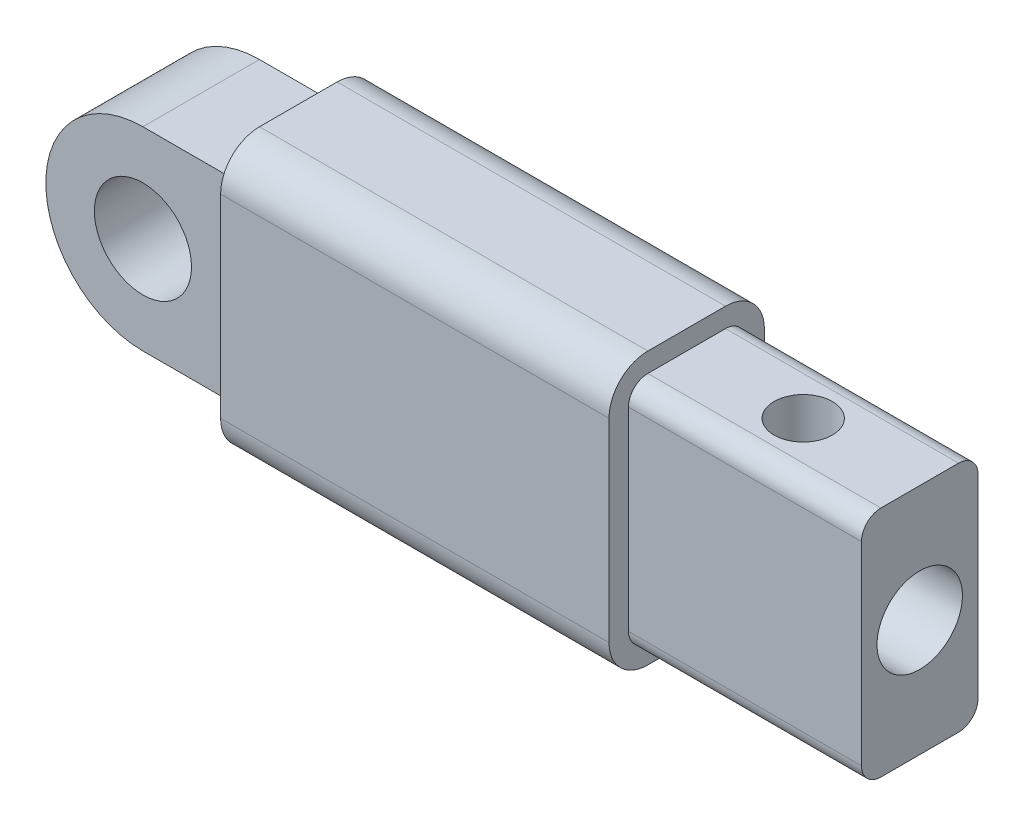
from build123d import *

# Parameters (mm, degrees)
STRUCTURAL_MEMBER1_DEPTH = 100
BOSS_EXTRUDE1_DEPTH      = 60
BOSS_EXTRUDE1_DEPTH_BACK = 150
SKETCH20_R               = 11
CUT_EXTRUDE6_DEPTH       = 30
SKETCH21_R               = 7.5
CUT_EXTRUDE7_DEPTH       = 174.853386507
CUT_EXTRUDE11_DEPTH      = 168.48134234
CUT_EXTRUDE11_DEPTH_BACK = 168.48134234
SKETCH23_R               = 12.5
CUT_EXTRUDE12_DEPTH      = 168.48134234


with BuildPart() as part:
    # Sketch11 → Structural Member1 (new body)
    with BuildSketch(Plane(origin=(0, 0, 0), x_dir=(0, 0, -1), z_dir=(1, 0, 0))):
        with BuildLine():
            Line((-10, -35), (10, -35))
            ThreePointArc((10, -35), (17.071067812, -32.071067812), (20, -25))
            Line((20, -25), (20, 25))
            ThreePointArc((20, 25), (17.071067812, 32.071067812), (10, 35))
            Line((10, 35), (-10, 35))
            ThreePointArc((-10, 35), (-17.071067812, 32.071067812), (-20, 25))
            Line((-20, 25), (-20, -25))
            ThreePointArc((-20, -25), (-17.071067812, -32.071067812), (-10, -35))
        make_face()
        with BuildLine():
            Line((-10, -30), (10, -30))
            ThreePointArc((10, -30), (13.535533906, -28.535533906), (15, -25))
            Line((15, -25), (15, 25))
            ThreePointArc((15, 25), (13.535533906, 28.535533906), (10, 30))
            Line((10, 30), (-10, 30))
            ThreePointArc((-10, 30), (-13.535533906, 28.535533906), (-15, 25))
            Line((-15, 25), (-15, -25))
            ThreePointArc((-15, -25), (-13.535533906, -28.535533906), (-10, -30))
        make_face(mode=Mode.SUBTRACT)
    extrude(amount=STRUCTURAL_MEMBER1_DEPTH)


with BuildPart() as body_2:
    # Sketch16 → Boss-Extrude1 (new, two sides)
    with BuildSketch(Plane(origin=(100, 0, 0), x_dir=(0, 0, -1), z_dir=(1, 0, 0))) as boss_extrude1_sk:
        with BuildLine():
            Line((15, -25), (15, 25))
            ThreePointArc((15, 25), (13.535533906, 28.535533906), (10, 30))
            Line((10, 30), (-10, 30))
            ThreePointArc((-10, 30), (-13.535533906, 28.535533906), (-15, 25))
            Line((-15, 25), (-15, -25))
            ThreePointArc((-15, -25), (-13.535533906, -28.535533906), (-10, -30))
            Line((-10, -30), (10, -30))
            ThreePointArc((10, -30), (13.535533906, -28.535533906), (15, -25))
        make_face()
    extrude(amount=BOSS_EXTRUDE1_DEPTH)
    extrude(boss_extrude1_sk.sketch, amount=-BOSS_EXTRUDE1_DEPTH_BACK)

    # Sketch20 → Cut-Extrude6 (cut)
    with BuildSketch(Plane(origin=(160, 0, 0), x_dir=(0, 0, -1), z_dir=(1, 0, 0))):
        Circle(SKETCH20_R)
    extrude(amount=-CUT_EXTRUDE6_DEPTH, mode=Mode.SUBTRACT)

    # Sketch21 → Cut-Extrude7 (cut, through all)
    with BuildSketch(Plane(origin=(0, 30, 0), x_dir=(1, 0, 0), z_dir=(0, 1, 0))):
        with Locations(Location((130, 0, 0), (0, 0, 270))):
            Circle(SKETCH21_R)
    extrude(amount=-CUT_EXTRUDE7_DEPTH, mode=Mode.SUBTRACT)

    # Sketch22 → Cut-Extrude11 (cut, two sides)
    with BuildSketch(Plane(origin=(0, 0, -15), x_dir=(-1, 0, 0), z_dir=(0, 0, -1))) as cut_extrude11_sk:
        with BuildLine():
            Line((0, 394.284984115), (0, 35))
            Line((0, 35), (0, 25))
            Line((0, 25), (25, 25))
            ThreePointArc((25, 25), (50, 0), (25, -25))
            Line((25, -25), (0, -25))
            Line((0, -25), (0, -30))
            Line((0, -30), (0, -389.284984115))
            Line((0, -389.284984115), (718.569968229, -389.284984115))
            Line((718.569968229, -389.284984115), (718.569968229, 394.284984115))
            Line((718.569968229, 394.284984115), (0, 394.284984115))
        make_face()
    extrude(amount=CUT_EXTRUDE11_DEPTH, mode=Mode.SUBTRACT)
    extrude(cut_extrude11_sk.sketch, amount=-CUT_EXTRUDE11_DEPTH_BACK, mode=Mode.SUBTRACT)

    # Sketch23 → Cut-Extrude12 (cut, through all)
    with BuildSketch(Plane(origin=(0, 0, -15), x_dir=(-1, 0, 0), z_dir=(0, 0, -1))):
        with Locations((25, 0)):
            Circle(SKETCH23_R)
    extrude(amount=-CUT_EXTRUDE12_DEPTH, mode=Mode.SUBTRACT)


solid = Compound([part.part, body_2.part])
